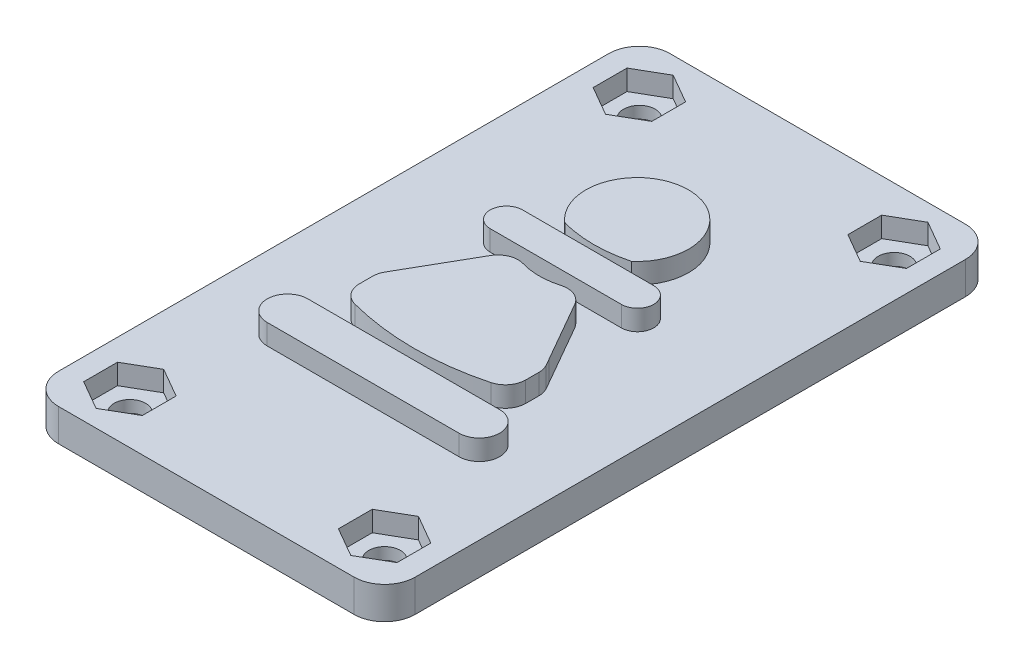
from build123d import *

# Parameters (mm, degrees)
SKETCH1_W             = 35
SKETCH1_H             = 60
SKETCH1_R             = 1.55
BOSS_EXTRUDE1_DEPTH   = 3.175
CUT_EXTRUDE1_START    = 3.175
SKETCH1_3_R           = 1.55
CUT_EXTRUDE1_DEPTH    = 2
BOSS_EXTRUDE2_DEPTH   = 2
BOSS_EXTRUDE2_2_DEPTH = 2
BOSS_EXTRUDE2_3_DEPTH = 2
BOSS_EXTRUDE2_4_DEPTH = 2
FILLET1_R             = 2
FILLET2_R             = 3


with BuildPart() as part:
    # Sketch1 → Boss-Extrude1 (new body)
    with BuildSketch(Plane(origin=(0, 0, 0), x_dir=(1, 0, 0), z_dir=(0, 1, 0))):
        Rectangle(SKETCH1_W, SKETCH1_H)
        Polygon((15.375, -23.340117976), (12.5, -21.680235952), (9.625, -23.340117976), (9.625, -26.659882024), (12.5, -28.319764048), (15.375, -26.659882024), align=None, mode=Mode.SUBTRACT)
        Polygon((-15.375, -26.659882024), (-12.5, -28.319764048), (-9.625, -26.659882024), (-9.625, -23.340117976), (-12.5, -21.680235952), (-15.375, -23.340117976), align=None, mode=Mode.SUBTRACT)
        Polygon((15.375, 26.659882024), (12.5, 28.319764048), (9.625, 26.659882024), (9.625, 23.340117976), (12.5, 21.680235952), (15.375, 23.340117976), align=None, mode=Mode.SUBTRACT)
        Polygon((-9.625, 26.659882024), (-12.5, 28.319764048), (-15.375, 26.659882024), (-15.375, 23.340117976), (-12.5, 21.680235952), (-9.625, 23.340117976), align=None, mode=Mode.SUBTRACT)
        Polygon((-9.625, 23.340117976), (-9.625, 26.659882024), (-12.5, 28.319764048), (-15.375, 26.659882024), (-15.375, 23.340117976), (-12.5, 21.680235952), align=None)
        with Locations((-12.5, 25)):
            Circle(SKETCH1_R, mode=Mode.SUBTRACT)
        Polygon((15.375, 23.340117976), (15.375, 26.659882024), (12.5, 28.319764048), (9.625, 26.659882024), (9.625, 23.340117976), (12.5, 21.680235952), align=None)
        with Locations((12.5, 25)):
            Circle(SKETCH1_R, mode=Mode.SUBTRACT)
        Polygon((15.375, -26.659882024), (15.375, -23.340117976), (12.5, -21.680235952), (9.625, -23.340117976), (9.625, -26.659882024), (12.5, -28.319764048), align=None)
        with Locations((12.5, -25)):
            Circle(SKETCH1_R, mode=Mode.SUBTRACT)
        Polygon((-15.375, -23.340117976), (-15.375, -26.659882024), (-12.5, -28.319764048), (-9.625, -26.659882024), (-9.625, -23.340117976), (-12.5, -21.680235952), align=None)
        with Locations((-12.5, -25)):
            Circle(SKETCH1_R, mode=Mode.SUBTRACT)
    extrude(amount=BOSS_EXTRUDE1_DEPTH)

    # Sketch1_3 → Cut-Extrude1 (cut)
    with BuildSketch(Plane(origin=(0, 0, 0), x_dir=(1, 0, 0), z_dir=(0, 1, 0)).offset(CUT_EXTRUDE1_START)):
        Polygon((-15.375, -23.340117976), (-15.375, -26.659882024), (-12.5, -28.319764048), (-9.625, -26.659882024), (-9.625, -23.340117976), (-12.5, -21.680235952), align=None)
        with Locations((-12.5, -25)):
            Circle(SKETCH1_3_R, mode=Mode.SUBTRACT)
        Polygon((-9.625, 23.340117976), (-9.625, 26.659882024), (-12.5, 28.319764048), (-15.375, 26.659882024), (-15.375, 23.340117976), (-12.5, 21.680235952), align=None)
        with Locations((-12.5, 25)):
            Circle(SKETCH1_3_R, mode=Mode.SUBTRACT)
        Polygon((15.375, 23.340117976), (15.375, 26.659882024), (12.5, 28.319764048), (9.625, 26.659882024), (9.625, 23.340117976), (12.5, 21.680235952), align=None)
        with Locations((12.5, 25)):
            Circle(SKETCH1_3_R, mode=Mode.SUBTRACT)
        Polygon((15.375, -26.659882024), (15.375, -23.340117976), (12.5, -21.680235952), (9.625, -23.340117976), (9.625, -26.659882024), (12.5, -28.319764048), align=None)
        with Locations((12.5, -25)):
            Circle(SKETCH1_3_R, mode=Mode.SUBTRACT)
    extrude(amount=-CUT_EXTRUDE1_DEPTH, mode=Mode.SUBTRACT)

    # Fillet2
    fillet2_edges = [part.edges().sort_by_distance(p)[0] for p in [
        (-17.5, 1.5875, 30),
        (-17.5, 1.5875, -30),
        (17.5, 1.5875, -30),
        (17.5, 1.5875, 30),
    ]]
    fillet(fillet2_edges, radius=FILLET2_R)


with BuildPart() as body_2:
    # Sketch2 → Boss-Extrude2 (new body)
    with BuildSketch(Plane(origin=(0, 3.175, 0), x_dir=(1, 0, 0), z_dir=(0, 1, 0))):
        with BuildLine():
            Line((-3.269392663, 3.546359145), (-7.534974208, -3.894449428))
            ThreePointArc((-7.534974208, -3.894449428), (-7.852446436, -4.453420618), (-8.165429983, -5.014917462))
            Line((-8.165429983, -5.014917462), (-8.165429983, -8.310188106))
            ThreePointArc((-8.165429983, -8.310188106), (0, -9.6177262), (8.165429983, -8.310188106))
            Line((8.165429983, -8.310188106), (8.165429983, -5.014917462))
            ThreePointArc((8.165429983, -5.014917462), (7.852446436, -4.453420618), (7.534974208, -3.894449428))
            Line((7.534974208, -3.894449428), (3.269392663, 3.546359145))
            ThreePointArc((3.269392663, 3.546359145), (0, 2.675698868), (-3.269392663, 3.546359145))
        make_face()
    extrude(amount=BOSS_EXTRUDE2_DEPTH)

    # Fillet1
    fillet1_edges = [body_2.edges().sort_by_distance(p)[0] for p in [
        (-3.269392663, 4.175, -3.546359145),
        (3.269392663, 4.175, -3.546359145),
        (8.165429983, 4.175, 5.014917462),
        (8.165429983, 4.175, 8.310188106),
        (-8.165429983, 4.175, 8.310188106),
        (-8.165429983, 4.175, 5.014917462),
    ]]
    fillet(fillet1_edges, radius=FILLET1_R)


with BuildPart() as body_3:
    # Sketch2 → Boss-Extrude2 2 (new body)
    with BuildSketch(Plane(origin=(0, 3.175, 0), x_dir=(1, 0, 0), z_dir=(0, 1, 0))):
        with BuildLine():
            Line((-6.434445122, 7.478486551), (6.434445122, 7.478486551))
            ThreePointArc((6.434445122, 7.478486551), (8.025508824, 5.887422848), (6.434445122, 4.296359145))
            Line((6.434445122, 4.296359145), (-6.434445122, 4.296359145))
            ThreePointArc((-6.434445122, 4.296359145), (-8.025508824, 5.887422848), (-6.434445122, 7.478486551))
        make_face()
    extrude(amount=BOSS_EXTRUDE2_2_DEPTH)


with BuildPart() as body_4:
    # Sketch2 → Boss-Extrude2 3 (new body)
    with BuildSketch(Plane(origin=(0, 3.175, 0), x_dir=(1, 0, 0), z_dir=(0, 1, 0))):
        with BuildLine():
            Line((-9.411894665, -10.6177262), (9.411894665, -10.6177262))
            ThreePointArc((9.411894665, -10.6177262), (11.411894665, -12.6177262), (9.411894665, -14.6177262))
            Line((9.411894665, -14.6177262), (-9.411894665, -14.6177262))
            ThreePointArc((-9.411894665, -14.6177262), (-11.411894665, -12.6177262), (-9.411894665, -10.6177262))
        make_face()
    extrude(amount=BOSS_EXTRUDE2_3_DEPTH)


with BuildPart() as body_5:
    # Sketch2 → Boss-Extrude2 4 (new body)
    with BuildSketch(Plane(origin=(0, 3.175, 0), x_dir=(1, 0, 0), z_dir=(0, 1, 0))):
        with BuildLine():
            ThreePointArc((-3.269392663, 8.448517148), (0, 17.332791609), (3.269392663, 8.448517148))
            ThreePointArc((3.269392663, 8.448517148), (0, 8.025408307), (-3.269392663, 8.448517148))
        make_face()
    extrude(amount=BOSS_EXTRUDE2_4_DEPTH)


solid = Compound([part.part, body_2.part, body_3.part, body_4.part, body_5.part])
